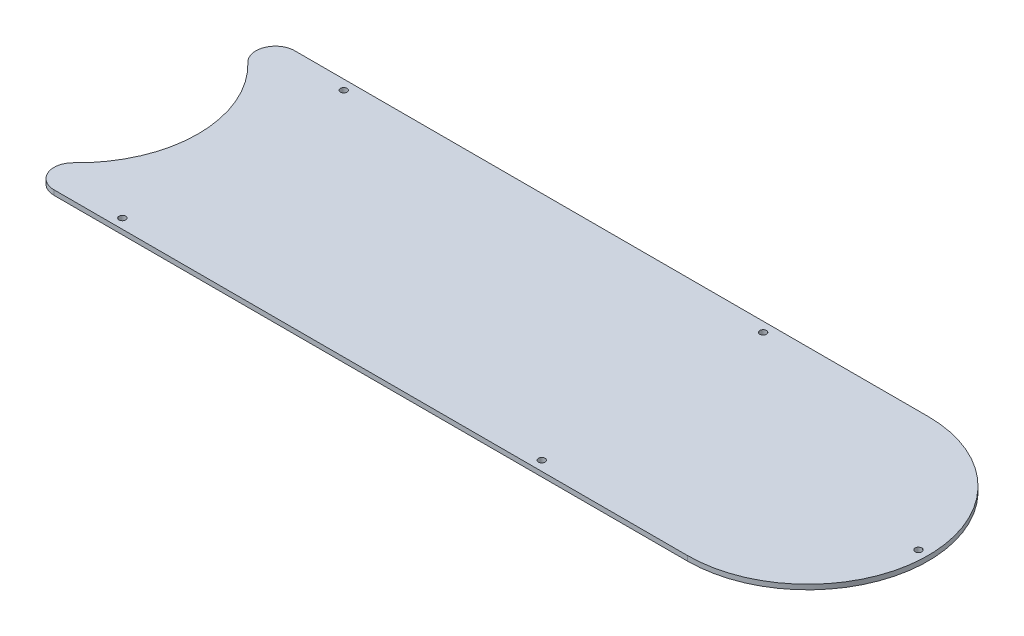
from build123d import *

# Parameters (mm, degrees)
SKETCH1_R           = 1.0922
BOSS_EXTRUDE1_DEPTH = 1.5875
FILLET1_R           = 6.35


with BuildPart() as part:
    # Sketch1 → Boss-Extrude1 (new body)
    with BuildSketch(Plane(origin=(0, 0, 0), x_dir=(1, 0, 0), z_dir=(0, 1, 0))):
        with BuildLine():
            Line((238.76, 39.37), (0, 39.37))
            ThreePointArc((0, 39.37), (39.37, 0), (0, -39.37))
            Line((0, -39.37), (238.76, -39.37))
            ThreePointArc((238.76, -39.37), (278.13, 0), (238.76, 39.37))
        make_face()
        with Locations((274.955, 0)):
            Circle(SKETCH1_R, mode=Mode.SUBTRACT)
        with Locations((187.96, 36.195)):
            Circle(SKETCH1_R, mode=Mode.SUBTRACT)
        with Locations((50.8, 36.195)):
            Circle(SKETCH1_R, mode=Mode.SUBTRACT)
        with Locations((50.8, -36.195)):
            Circle(SKETCH1_R, mode=Mode.SUBTRACT)
        with Locations((187.96, -36.195)):
            Circle(SKETCH1_R, mode=Mode.SUBTRACT)
    extrude(amount=BOSS_EXTRUDE1_DEPTH)

    # Fillet1
    fillet1_edges = [part.edges().sort_by_distance(p)[0] for p in [
        (0, 0.79375, 39.37),
        (0, 0.79375, -39.37),
    ]]
    fillet(fillet1_edges, radius=FILLET1_R)


solid = part.part
